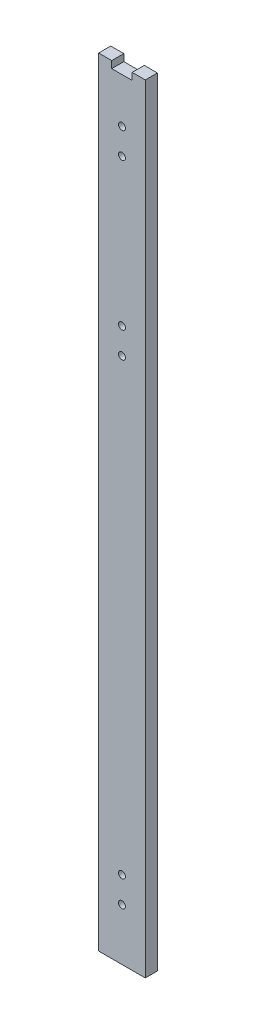
from build123d import *

# Parameters (mm, degrees)
SKETCH_1_W          = 27
SKETCH_1_H          = 7
EXTRUDE_1_DEPTH     = 450
SKETCH_2_W          = 11.82792619
SKETCH_2_H          = 8.082032634
CUT_EXTRUDE_1_DEPTH = 8
SKETCH_3_R          = 2
CUT_EXTRUDE_2_DEPTH = 8


with BuildPart() as part:
    # 草图1 → 凸台-拉伸1 (new body)
    with BuildSketch(Plane(origin=(0, 0, 0), x_dir=(1, 0, 0), z_dir=(0, 1, 0))):
        Rectangle(SKETCH_1_W, SKETCH_1_H)
    extrude(amount=EXTRUDE_1_DEPTH)

    # 草图2 → 切除-拉伸1 (cut, through all)
    with BuildSketch(Plane(origin=(0, 0, -3.5), x_dir=(-1, 0, 0), z_dir=(0, 0, -1))):
        with Locations((0, 450)):
            Rectangle(SKETCH_2_W, SKETCH_2_H)
    extrude(amount=-CUT_EXTRUDE_1_DEPTH, mode=Mode.SUBTRACT)

    # 草图3 → 切除-拉伸2 (cut, through all)
    with BuildSketch(Plane(origin=(0, 0, -3.5), x_dir=(-1, 0, 0), z_dir=(0, 0, -1))):
        with Locations((0, 420)):
            Circle(SKETCH_3_R)
        with Locations((0, 405)):
            Circle(SKETCH_3_R)
        with Locations((0, 320)):
            Circle(SKETCH_3_R)
        with Locations((0, 305)):
            Circle(SKETCH_3_R)
        with Locations((0, 30)):
            Circle(SKETCH_3_R)
        with Locations((0, 45)):
            Circle(SKETCH_3_R)
    extrude(amount=-CUT_EXTRUDE_2_DEPTH, mode=Mode.SUBTRACT)


solid = part.part
